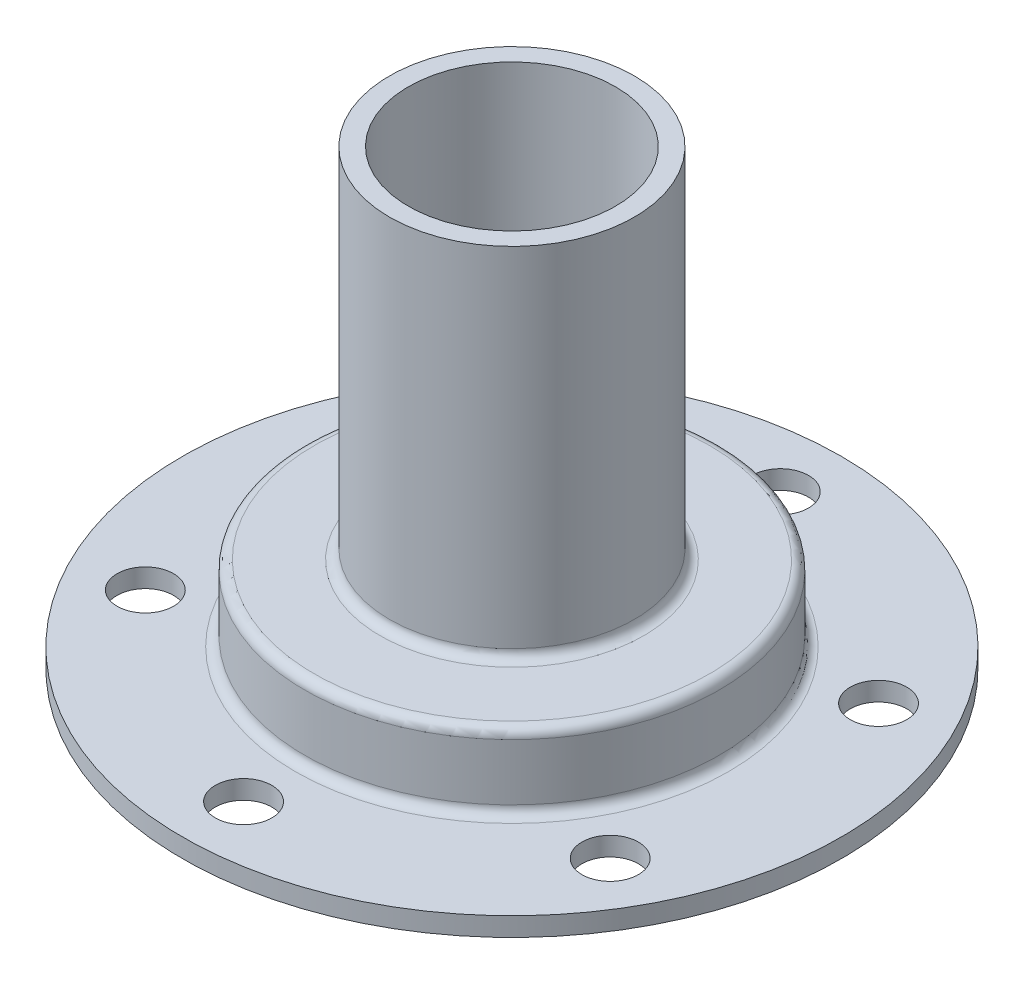
from build123d import *

# Parameters (mm, degrees)
SKETCH_2_R          = 3
CUT_EXTRUDE_1_DEPTH = 3
SKETCH_3_R          = 2.5
CUT_EXTRUDE_2_DEPTH = 36


with BuildPart() as part:
    # 草图1 → 旋转1 (revolve)
    with BuildSketch(Plane.XY):
        with BuildLine():
            Line((20, 0), (35, 0))
            Line((35, 0), (35, 2))
            Line((35, 2), (23, 2))
            ThreePointArc((23, 2), (22.292893219, 2.292893219), (22, 3))
            Line((22, 3), (22, 9))
            ThreePointArc((22, 9), (21.707106781, 9.707106781), (21, 10))
            Line((21, 10), (14, 10))
            ThreePointArc((14, 10), (13.292893219, 10.292893219), (13, 11))
            Line((13, 11), (13, 48))
            Line((13, 48), (11, 48))
            Line((11, 48), (11, 8))
            Line((11, 8), (19, 8))
            ThreePointArc((19, 8), (19.707106781, 7.707106781), (20, 7))
            Line((20, 7), (20, 0))
        make_face()
    revolve(axis=Axis((0, 0, 0), (0, 1, 0)))

    # 草图2 → 切除-拉伸1 (cut, through all)
    with BuildSketch(Plane(origin=(0, 2, 0), x_dir=(1, 0, 0), z_dir=(0, 1, 0))):
        with Locations((0, 28.5)):
            Circle(SKETCH_2_R)
        with Locations((24.681724008, 14.25)):
            Circle(SKETCH_2_R)
        with Locations((24.681724008, -14.25)):
            Circle(SKETCH_2_R)
        with Locations((0, -28.5)):
            Circle(SKETCH_2_R)
        with Locations((-24.681724008, -14.25)):
            Circle(SKETCH_2_R)
        with Locations((-24.681724008, 14.25)):
            Circle(SKETCH_2_R)
    extrude(amount=-CUT_EXTRUDE_1_DEPTH, mode=Mode.SUBTRACT)

    # 草图3 → 切除-拉伸2 (cut, through all)
    with BuildSketch(Plane(origin=(0, 0, 0), x_dir=(0, 0, -1), z_dir=(1, 0, 0))):
        with Locations((0, 31.335996188)):
            Circle(SKETCH_3_R)
    extrude(amount=-CUT_EXTRUDE_2_DEPTH, mode=Mode.SUBTRACT)


solid = part.part
